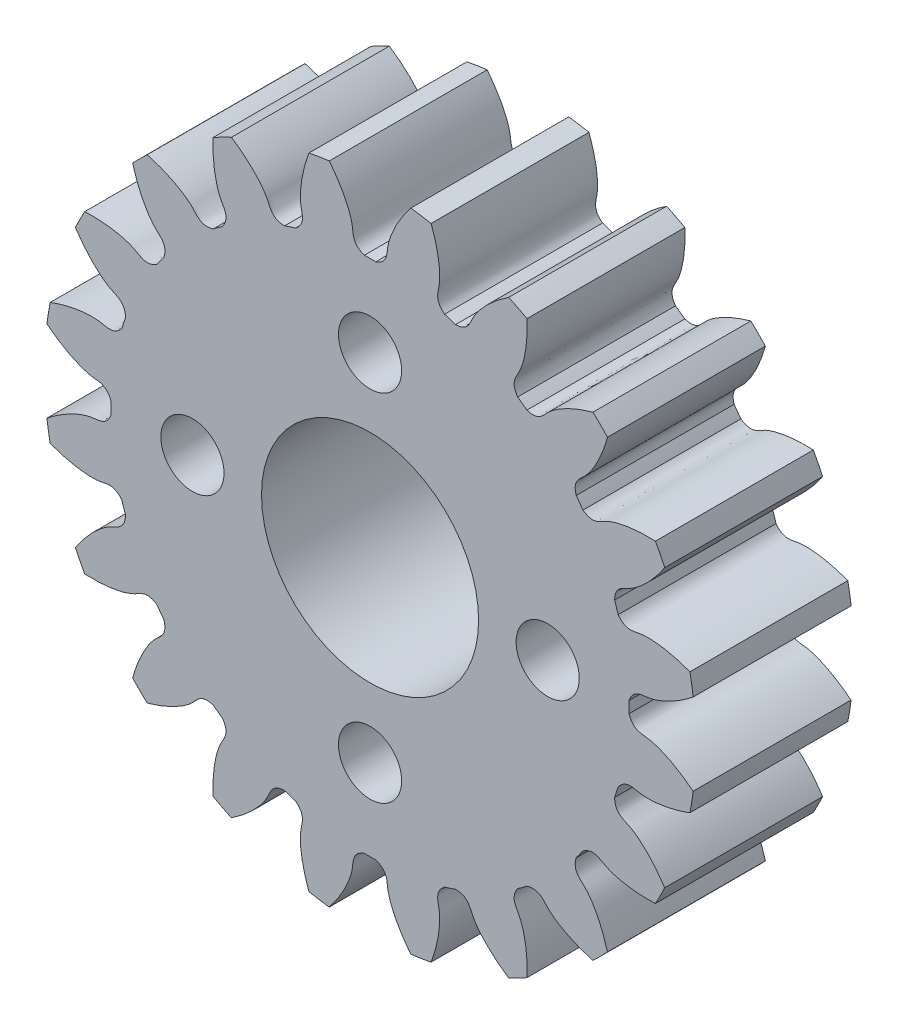
from build123d import *

# Parameters (mm, degrees)
SKETCH_1_R               = 16.5
EXTRUDE_1_DEPTH          = 10
CUT_EXTRUDE_1_DEPTH      = 11
PATTERN_CIRCULAR_1_COUNT = 20
SKETCH_4_R               = 1.6
SKETCH_4_R_2             = 5.5
CUT_EXTRUDE_2_DEPTH      = 11.0000001
CUT_EXTRUDE_3_DEPTH      = 2


with BuildPart() as part:
    # Sketch 1 → Extrude 1 (new body)
    with BuildSketch(Plane.XY):
        Circle(SKETCH_1_R)
    extrude(amount=EXTRUDE_1_DEPTH)

    # Sketch 2 → Cut-Extrude 1 (cut, through all)
    with BuildSketch(Plane.XY):
        with BuildLine():
            ThreePointArc((0.289974901, 13.121796354), (0, 13.125), (-0.289974901, 13.121796354))
            add(Edge.make_bspline(
                [(-0.289974901, 13.121796354), (-0.916784107, 13.340213268), (-0.835626149, 13.780670548), (-0.919345585, 14.205014104), (-0.928338279, 14.246334921), (-0.939466335, 14.292951923), (-0.952938145, 14.344795254), (-0.96896871, 14.401787245), (-0.987768083, 14.463844242), (-1.009544807, 14.5308761), (-1.034504625, 14.602786421), (-1.06285065, 14.679472568), (-1.094783098, 14.760825751), (-1.130499153, 14.846731096), (-1.170192797, 14.937067727), (-1.214054647, 15.031708847), (-1.2622718, 15.130521826), (-1.315027675, 15.233368292), (-1.372501858, 15.340104225), (-1.434869948, 15.450580056), (-1.502303414, 15.564640771), (-1.574969439, 15.682126017), (-1.653030782, 15.802870208), (-1.736645634, 15.926702646), (-1.825967477, 16.05344763), (-1.921144951, 16.182924586), (-2.022321721, 16.314948181), (-2.129636342, 16.449328459), (-2.24322214, 16.585870967), (-2.363207078, 16.724376892), (-2.489713645, 16.864643194), (-2.622858733, 17.006462752), (-2.762753527, 17.149624504), (-2.909503389, 17.29391359), (-3.06320776, 17.439111509), (-3.223960048, 17.584996263), (-3.391847534, 17.731342516), (-3.566951278, 17.877921749), (-3.749346018, 18.024502419), (-3.939100102, 18.170850122), (-4.136275349, 18.31672776), (-4.412210386, 18.512459802), (-4.625898619, 18.654498902), (-4.771736973, 18.747377789)],
                knots=[0, 0, 0, 0, 0.165916003, 0.170905922, 0.176663519, 0.183188797, 0.190481754, 0.198542391, 0.207370708, 0.216966704, 0.22733038, 0.238461736, 0.250360771, 0.263027487, 0.276461881, 0.290663956, 0.30563371, 0.321371144, 0.337876258, 0.355149051, 0.373189524, 0.391997677, 0.411573509, 0.431917021, 0.453028213, 0.474907084, 0.497553636, 0.520967867, 0.545149777, 0.570099367, 0.595816637, 0.622301587, 0.649554216, 0.677574526, 0.706362514, 0.735918183, 0.766241531, 0.797332559, 0.829191267, 0.861817654, 0.895211721, 0.929373468, 1, 1, 1, 1], degree=3))
            ThreePointArc((-4.771736973, 18.747377789), (0, 19.345119481), (4.771736973, 18.747377789))
            add(Edge.make_bspline(
                [(0.289974901, 13.121796354), (0.916784107, 13.340213268), (0.835626149, 13.780670548), (0.919345585, 14.205014104), (0.928338279, 14.246334921), (0.939466335, 14.292951923), (0.952938145, 14.344795254), (0.96896871, 14.401787245), (0.987768083, 14.463844242), (1.009544807, 14.5308761), (1.034504625, 14.602786421), (1.06285065, 14.679472568), (1.094783098, 14.760825751), (1.130499153, 14.846731096), (1.170192797, 14.937067727), (1.214054647, 15.031708847), (1.2622718, 15.130521826), (1.315027675, 15.233368292), (1.372501858, 15.340104225), (1.434869948, 15.450580056), (1.502303414, 15.564640771), (1.574969439, 15.682126017), (1.653030782, 15.802870208), (1.736645634, 15.926702646), (1.825967477, 16.05344763), (1.921144951, 16.182924586), (2.022321721, 16.314948181), (2.129636342, 16.449328459), (2.24322214, 16.585870967), (2.363207078, 16.724376892), (2.489713645, 16.864643194), (2.622858733, 17.006462752), (2.762753527, 17.149624504), (2.909503389, 17.29391359), (3.06320776, 17.439111509), (3.223960048, 17.584996263), (3.391847534, 17.731342516), (3.566951278, 17.877921749), (3.749346018, 18.024502419), (3.939100102, 18.170850122), (4.136275349, 18.31672776), (4.412210386, 18.512459802), (4.625898619, 18.654498902), (4.771736973, 18.747377789)],
                knots=[0, 0, 0, 0, 0.165916003, 0.170905922, 0.176663519, 0.183188797, 0.190481754, 0.198542391, 0.207370708, 0.216966704, 0.22733038, 0.238461736, 0.250360771, 0.263027487, 0.276461881, 0.290663956, 0.30563371, 0.321371144, 0.337876258, 0.355149051, 0.373189524, 0.391997677, 0.411573509, 0.431917021, 0.453028213, 0.474907084, 0.497553636, 0.520967867, 0.545149777, 0.570099367, 0.595816637, 0.622301587, 0.649554216, 0.677574526, 0.706362514, 0.735918183, 0.766241531, 0.797332559, 0.829191267, 0.861817654, 0.895211721, 0.929373468, 1, 1, 1, 1], degree=3))
        make_face()
    cut_extrude_1 = extrude(amount=CUT_EXTRUDE_1_DEPTH, mode=Mode.SUBTRACT)

    # Pattern Circular 1: Cut-Extrude 1 ×20 about axis
    pattern_circular_1_axis = Axis((0, 0, -0.6), (0, 0, 1))
    for i in range(1, PATTERN_CIRCULAR_1_COUNT):
        add(cut_extrude_1.rotate(pattern_circular_1_axis, i * 360 / PATTERN_CIRCULAR_1_COUNT), mode=Mode.SUBTRACT)

    # Sketch 4 → Cut-Extrude 2 (cut, through all)
    with BuildSketch(Plane.XY.offset(10)):
        with Locations((0, 9)):
            Circle(SKETCH_4_R)
        with Locations((9, 0)):
            Circle(SKETCH_4_R)
        with Locations((0, -9)):
            Circle(SKETCH_4_R)
        with Locations((-9, 0)):
            Circle(SKETCH_4_R)
        Circle(SKETCH_4_R_2)
    extrude(amount=-CUT_EXTRUDE_2_DEPTH, mode=Mode.SUBTRACT)

    # Sketch 5 → Cut-Extrude 3 (cut)
    with BuildSketch(Plane.XY.offset(10)):
        with BuildLine():
            ThreePointArc((-3.779075551, 12.5691771), (-4.055848051, 12.482616776), (-4.330640589, 12.389962756))
            add(Edge.make_bspline(
                [(-4.330640589, 12.389962756), (-4.994266108, 12.403994888), (-5.053189088, 12.847973843), (-5.271724722, 13.239628764), (-5.302663012, 13.291214284), (-5.339083547, 13.34823692), (-5.371941014, 13.397485807), (-5.423497094, 13.471517648), (-5.49921148, 13.573335394), (-5.605484405, 13.704968764), (-5.731774494, 13.849236955), (-5.879238162, 14.004722621), (-6.048949836, 14.16993691), (-6.241897634, 14.343324035), (-6.458979876, 14.523265777), (-6.701001692, 14.708086237), (-6.893090101, 14.842979081), (-7.003862907, 14.916928497), (-7.024032405, 14.930270218)],
                knots=[0.492568302, 0.492568302, 0.492568302, 0.492568302, 0.658484305, 0.663474224, 0.675757099, 0.683050056, 0.691110693, 0.69993901, 0.719898682, 0.742929074, 0.769030183, 0.798202012, 0.83044456, 0.865757826, 0.904141811, 0.945596515, 0.990121938, 1, 1, 1, 1], degree=3))
            ThreePointArc((-7.024032405, 14.930270218), (-7.490843246, 14.701607649), (-7.950219677, 14.458354231))
            add(Edge.make_bspline(
                [(-7.950219677, 14.458354231), (-7.956066747, 14.325295461), (-7.960919092, 14.090601088), (-7.95307581, 13.761985862), (-7.935097664, 13.480595511), (-7.908236426, 13.222583055), (-7.874329309, 12.988172883), (-7.835215787, 12.777480054), (-7.798771221, 12.617089507), (-7.762130708, 12.476113624), (-7.732718373, 12.375039504), (-7.702513172, 12.282091307), (-7.681245996, 12.220836149), (-7.660715943, 12.16530613), (-7.635991116, 12.102324233), (-7.612442624, 12.046973423), (-7.424039159, 11.639965394), (-7.099486698, 11.33133142), (-7.478203758, 10.786199217)],
                knots=[0, 0, 0, 0, 0.054403485, 0.095858189, 0.134242174, 0.16955544, 0.201797988, 0.230969817, 0.257070926, 0.268969962, 0.290464994, 0.30006099, 0.308889307, 0.316949944, 0.324242901, 0.336525776, 0.341515695, 0.507431698, 0.507431698, 0.507431698, 0.507431698], degree=3))
            ThreePointArc((-7.478203758, 10.786199217), (-7.714681436, 10.618348051), (-7.947393003, 10.445313277))
            add(Edge.make_bspline(
                [(-7.947393003, 10.445313277), (-8.582874544, 10.253587065), (-8.776110671, 10.657627941), (-9.104978437, 10.962582681), (-9.150343301, 11.002082969), (-9.202602252, 11.045060153), (-9.249070303, 11.081745113), (-9.320980145, 11.136221873), (-9.42445222, 11.209659272), (-9.566200726, 11.302009906), (-9.730891061, 11.400191325), (-9.919185056, 11.502498201), (-10.131644473, 11.607182537), (-10.368728301, 11.712459343), (-10.630790839, 11.816512007), (-10.918079927, 11.917497856), (-11.142451042, 11.986429991), (-11.270653866, 12.022529386), (-11.293959017, 12.028985398)],
                knots=[0.492568302, 0.492568302, 0.492568302, 0.492568302, 0.658484305, 0.663474224, 0.675757099, 0.683050056, 0.691110693, 0.69993901, 0.719898682, 0.742929074, 0.769030183, 0.798202012, 0.83044456, 0.865757826, 0.904141811, 0.945596515, 0.990121938, 1, 1, 1, 1], degree=3))
            ThreePointArc((-11.293959017, 12.028985398), (-11.66726189, 11.66726189), (-12.028985398, 11.293959017))
            add(Edge.make_bspline(
                [(-12.028985398, 11.293959017), (-11.993428871, 11.165605763), (-11.925519176, 10.940898693), (-11.816512081, 10.630790749), (-11.712459448, 10.368728174), (-11.607182659, 10.131644325), (-11.502498347, 9.91918488), (-11.400191512, 9.730890834), (-11.315967266, 9.589612349), (-11.237556123, 9.466858859), (-11.17834971, 9.37982057), (-11.120900284, 9.300755502), (-11.081745113, 9.249070303), (-11.045060153, 9.202602252), (-11.002082969, 9.150343301), (-10.962582681, 9.104978437), (-10.657627941, 8.776110671), (-10.253587065, 8.582874544), (-10.445313277, 7.947393003)],
                knots=[0, 0, 0, 0, 0.054403485, 0.095858189, 0.134242174, 0.16955544, 0.201797988, 0.230969817, 0.257070926, 0.268969962, 0.290464994, 0.30006099, 0.308889307, 0.316949944, 0.324242901, 0.336525776, 0.341515695, 0.507431698, 0.507431698, 0.507431698, 0.507431698], degree=3))
            ThreePointArc((-10.445313277, 7.947393003), (-10.618348051, 7.714681436), (-10.786199217, 7.478203758))
            add(Edge.make_bspline(
                [(-10.786199217, 7.478203758), (-11.33133142, 7.099486698), (-11.639965394, 7.424039159), (-12.046973423, 7.612442624), (-12.102324233, 7.635991116), (-12.16530613, 7.660715943), (-12.220836149, 7.681245996), (-12.306060717, 7.71083511), (-12.427161912, 7.748703597), (-12.590510669, 7.792731572), (-12.777480211, 7.835215538), (-12.988173006, 7.874329115), (-13.222583157, 7.908236264), (-13.480595599, 7.935097524), (-13.761985925, 7.953075711), (-14.066420428, 7.960341751), (-14.30111124, 7.956565619), (-14.434194698, 7.951281332), (-14.458354231, 7.950219677)],
                knots=[0.492568302, 0.492568302, 0.492568302, 0.492568302, 0.658484305, 0.663474224, 0.675757099, 0.683050056, 0.691110693, 0.69993901, 0.719898682, 0.742929074, 0.769030183, 0.798202012, 0.83044456, 0.865757826, 0.904141811, 0.945596515, 0.990121938, 1, 1, 1, 1], degree=3))
            ThreePointArc((-14.458354231, 7.950219677), (-14.701607649, 7.490843246), (-14.930270218, 7.024032405))
            add(Edge.make_bspline(
                [(-14.930270218, 7.024032405), (-14.856790614, 6.912948778), (-14.722766352, 6.720224904), (-14.52326582, 6.458979768), (-14.343324096, 6.24189748), (-14.169936981, 6.048949658), (-14.004722705, 5.879237949), (-13.849237063, 5.731774221), (-13.725477592, 5.623437121), (-13.612971249, 5.530921989), (-13.529766293, 5.466439445), (-13.450696193, 5.408996946), (-13.397485807, 5.371941014), (-13.34823692, 5.339083547), (-13.291214284, 5.302663012), (-13.239628764, 5.271724722), (-12.847973843, 5.053189088), (-12.403994888, 4.994266108), (-12.389962756, 4.330640589)],
                knots=[0, 0, 0, 0, 0.054403485, 0.095858189, 0.134242174, 0.16955544, 0.201797988, 0.230969817, 0.257070926, 0.268969962, 0.290464994, 0.30006099, 0.308889307, 0.316949944, 0.324242901, 0.336525776, 0.341515695, 0.507431698, 0.507431698, 0.507431698, 0.507431698], degree=3))
            ThreePointArc((-12.389962756, 4.330640589), (-12.482616776, 4.055848051), (-12.5691771, 3.779075551))
            add(Edge.make_bspline(
                [(-12.5691771, 3.779075551), (-12.970598627, 3.250439109), (-13.364419205, 3.463733699), (-13.809726715, 3.517143644), (-13.869645348, 3.522435249), (-13.937185083, 3.526487481), (-13.996341404, 3.528853002), (-14.086538325, 3.530658082), (-14.213414411, 3.529250826), (-14.382373703, 3.520646377), (-14.573320573, 3.503274264), (-14.785788088, 3.475365832), (-15.019203275, 3.435176726), (-15.272888275, 3.380993074), (-15.546061943, 3.311136952), (-15.837841691, 3.223971932), (-16.059879028, 3.147857168), (-16.184815984, 3.101706462), (-16.207464996, 3.093231062)],
                knots=[0.492568302, 0.492568302, 0.492568302, 0.492568302, 0.658484305, 0.663474224, 0.675757099, 0.683050056, 0.691110693, 0.69993901, 0.719898682, 0.742929074, 0.769030183, 0.798202012, 0.83044456, 0.865757826, 0.904141811, 0.945596515, 0.990121938, 1, 1, 1, 1], degree=3))
            ThreePointArc((-16.207464996, 3.093231062), (-16.29685762, 2.581168673), (-16.370076163, 2.066544562))
            add(Edge.make_bspline(
                [(-16.370076163, 2.066544562), (-16.265866178, 1.9836042), (-16.078846579, 1.841728679), (-15.80838111, 1.654918845), (-15.570164245, 1.504066371), (-15.345639144, 1.374141652), (-15.136067228, 1.263790245), (-14.942622797, 1.171591611), (-14.79144254, 1.106800686), (-14.655853902, 1.053579939), (-14.556795084, 1.017965141), (-14.463844242, 0.987768083), (-14.401787245, 0.96896871), (-14.344795254, 0.952938145), (-14.279308941, 0.935921121), (-14.220687739, 0.922437862), (-13.780670548, 0.835626149), (-13.340213268, 0.916784107), (-13.121796354, 0.289974901)],
                knots=[0, 0, 0, 0, 0.054403485, 0.095858189, 0.134242174, 0.16955544, 0.201797988, 0.230969817, 0.257070926, 0.268969962, 0.290464994, 0.30006099, 0.308889307, 0.316949944, 0.324242901, 0.336525776, 0.341515695, 0.507431698, 0.507431698, 0.507431698, 0.507431698], degree=3))
            ThreePointArc((-13.121796354, 0.289974901), (-13.125, 0), (-13.121796354, -0.289974901))
            add(Edge.make_bspline(
                [(-13.121796354, -0.289974901), (-13.340213268, -0.916784107), (-13.780670548, -0.835626149), (-14.220687739, -0.922437862), (-14.279308941, -0.935921121), (-14.344795254, -0.952938145), (-14.401787245, -0.96896871), (-14.488127415, -0.995124359), (-14.608358878, -1.035669605), (-14.766389792, -1.096064215), (-14.942622778, -1.171591904), (-15.136067213, -1.263790473), (-15.345639132, -1.374141844), (-15.570164235, -1.504066536), (-15.808381103, -1.654918961), (-16.05894466, -1.827982723), (-16.246593961, -1.968985475), (-16.351154715, -2.051485048), (-16.370076163, -2.066544562)],
                knots=[0.492568302, 0.492568302, 0.492568302, 0.492568302, 0.658484305, 0.663474224, 0.675757099, 0.683050056, 0.691110693, 0.69993901, 0.719898682, 0.742929074, 0.769030183, 0.798202012, 0.83044456, 0.865757826, 0.904141811, 0.945596515, 0.990121938, 1, 1, 1, 1], degree=3))
            ThreePointArc((-16.370076163, -2.066544562), (-16.29685762, -2.581168673), (-16.207464996, -3.093231062))
            add(Edge.make_bspline(
                [(-16.207464996, -3.093231062), (-16.08272543, -3.139909377), (-15.861017274, -3.217048781), (-15.546061914, -3.311137065), (-15.272888234, -3.380993234), (-15.019203228, -3.435176912), (-14.785788031, -3.475366054), (-14.5733205, -3.503274549), (-14.409518034, -3.518177112), (-14.264119461, -3.526893856), (-14.15890335, -3.530154684), (-14.061170441, -3.530150403), (-13.996341404, -3.528853002), (-13.937185083, -3.526487481), (-13.869645348, -3.522435249), (-13.809726715, -3.517143644), (-13.364419205, -3.463733699), (-12.970598627, -3.250439109), (-12.5691771, -3.779075551)],
                knots=[0, 0, 0, 0, 0.054403485, 0.095858189, 0.134242174, 0.16955544, 0.201797988, 0.230969817, 0.257070926, 0.268969962, 0.290464994, 0.30006099, 0.308889307, 0.316949944, 0.324242901, 0.336525776, 0.341515695, 0.507431698, 0.507431698, 0.507431698, 0.507431698], degree=3))
            ThreePointArc((-12.5691771, -3.779075551), (-12.482616776, -4.055848051), (-12.389962756, -4.330640589))
            add(Edge.make_bspline(
                [(-12.389962756, -4.330640589), (-12.403994888, -4.994266108), (-12.847973843, -5.053189088), (-13.239628764, -5.271724722), (-13.291214284, -5.302663012), (-13.34823692, -5.339083547), (-13.397485807, -5.371941014), (-13.471517648, -5.423497094), (-13.573335394, -5.49921148), (-13.704968764, -5.605484405), (-13.849236955, -5.731774494), (-14.004722621, -5.879238162), (-14.16993691, -6.048949836), (-14.343324035, -6.241897634), (-14.523265777, -6.458979876), (-14.708086237, -6.701001692), (-14.842979081, -6.893090101), (-14.916928497, -7.003862907), (-14.930270218, -7.024032405)],
                knots=[0.492568302, 0.492568302, 0.492568302, 0.492568302, 0.658484305, 0.663474224, 0.675757099, 0.683050056, 0.691110693, 0.69993901, 0.719898682, 0.742929074, 0.769030183, 0.798202012, 0.83044456, 0.865757826, 0.904141811, 0.945596515, 0.990121938, 1, 1, 1, 1], degree=3))
            ThreePointArc((-14.930270218, -7.024032405), (-14.701607649, -7.490843246), (-14.458354231, -7.950219677))
            add(Edge.make_bspline(
                [(-14.458354231, -7.950219677), (-14.325295461, -7.956066747), (-14.090601088, -7.960919092), (-13.761985862, -7.95307581), (-13.480595511, -7.935097664), (-13.222583055, -7.908236426), (-12.988172883, -7.874329309), (-12.777480054, -7.835215787), (-12.617089507, -7.798771221), (-12.476113624, -7.762130708), (-12.375039504, -7.732718373), (-12.282091307, -7.702513172), (-12.220836149, -7.681245996), (-12.16530613, -7.660715943), (-12.102324233, -7.635991116), (-12.046973423, -7.612442624), (-11.639965394, -7.424039159), (-11.33133142, -7.099486698), (-10.786199217, -7.478203758)],
                knots=[0, 0, 0, 0, 0.054403485, 0.095858189, 0.134242174, 0.16955544, 0.201797988, 0.230969817, 0.257070926, 0.268969962, 0.290464994, 0.30006099, 0.308889307, 0.316949944, 0.324242901, 0.336525776, 0.341515695, 0.507431698, 0.507431698, 0.507431698, 0.507431698], degree=3))
            ThreePointArc((-10.786199217, -7.478203758), (-10.618348051, -7.714681436), (-10.445313277, -7.947393003))
            add(Edge.make_bspline(
                [(-10.445313277, -7.947393003), (-10.253587065, -8.582874544), (-10.657627941, -8.776110671), (-10.962582681, -9.104978437), (-11.002082969, -9.150343301), (-11.045060153, -9.202602252), (-11.081745113, -9.249070303), (-11.136221873, -9.320980145), (-11.209659272, -9.42445222), (-11.302009906, -9.566200726), (-11.400191325, -9.730891061), (-11.502498201, -9.919185056), (-11.607182537, -10.131644473), (-11.712459343, -10.368728301), (-11.816512007, -10.630790839), (-11.917497856, -10.918079927), (-11.986429991, -11.142451042), (-12.022529386, -11.270653866), (-12.028985398, -11.293959017)],
                knots=[0.492568302, 0.492568302, 0.492568302, 0.492568302, 0.658484305, 0.663474224, 0.675757099, 0.683050056, 0.691110693, 0.69993901, 0.719898682, 0.742929074, 0.769030183, 0.798202012, 0.83044456, 0.865757826, 0.904141811, 0.945596515, 0.990121938, 1, 1, 1, 1], degree=3))
            ThreePointArc((-12.028985398, -11.293959017), (-11.66726189, -11.66726189), (-11.293959017, -12.028985398))
            add(Edge.make_bspline(
                [(-11.293959017, -12.028985398), (-11.165605763, -11.993428871), (-10.940898693, -11.925519176), (-10.630790749, -11.816512081), (-10.368728174, -11.712459448), (-10.131644325, -11.607182659), (-9.91918488, -11.502498347), (-9.730890834, -11.400191512), (-9.589612349, -11.315967266), (-9.466858859, -11.237556123), (-9.37982057, -11.17834971), (-9.300755502, -11.120900284), (-9.249070303, -11.081745113), (-9.202602252, -11.045060153), (-9.150343301, -11.002082969), (-9.104978437, -10.962582681), (-8.776110671, -10.657627941), (-8.582874544, -10.253587065), (-7.947393003, -10.445313277)],
                knots=[0, 0, 0, 0, 0.054403485, 0.095858189, 0.134242174, 0.16955544, 0.201797988, 0.230969817, 0.257070926, 0.268969962, 0.290464994, 0.30006099, 0.308889307, 0.316949944, 0.324242901, 0.336525776, 0.341515695, 0.507431698, 0.507431698, 0.507431698, 0.507431698], degree=3))
            ThreePointArc((-7.947393003, -10.445313277), (-7.714681436, -10.618348051), (-7.478203758, -10.786199217))
            add(Edge.make_bspline(
                [(-7.478203758, -10.786199217), (-7.099486698, -11.33133142), (-7.424039159, -11.639965394), (-7.612442624, -12.046973423), (-7.635991116, -12.102324233), (-7.660715943, -12.16530613), (-7.681245996, -12.220836149), (-7.71083511, -12.306060717), (-7.748703597, -12.427161912), (-7.792731572, -12.590510669), (-7.835215538, -12.777480211), (-7.874329115, -12.988173006), (-7.908236264, -13.222583157), (-7.935097524, -13.480595599), (-7.953075711, -13.761985925), (-7.960341751, -14.066420428), (-7.956565619, -14.30111124), (-7.951281332, -14.434194698), (-7.950219677, -14.458354231)],
                knots=[0.492568302, 0.492568302, 0.492568302, 0.492568302, 0.658484305, 0.663474224, 0.675757099, 0.683050056, 0.691110693, 0.69993901, 0.719898682, 0.742929074, 0.769030183, 0.798202012, 0.83044456, 0.865757826, 0.904141811, 0.945596515, 0.990121938, 1, 1, 1, 1], degree=3))
            ThreePointArc((-7.950219677, -14.458354231), (-7.490843246, -14.701607649), (-7.024032405, -14.930270218))
            add(Edge.make_bspline(
                [(-7.024032405, -14.930270218), (-6.912948778, -14.856790614), (-6.720224904, -14.722766352), (-6.458979768, -14.52326582), (-6.24189748, -14.343324096), (-6.048949658, -14.169936981), (-5.879237949, -14.004722705), (-5.731774221, -13.849237063), (-5.623437121, -13.725477592), (-5.530921989, -13.612971249), (-5.466439445, -13.529766293), (-5.408996946, -13.450696193), (-5.371941014, -13.397485807), (-5.339083547, -13.34823692), (-5.302663012, -13.291214284), (-5.271724722, -13.239628764), (-5.053189088, -12.847973843), (-4.994266108, -12.403994888), (-4.330640589, -12.389962756)],
                knots=[0, 0, 0, 0, 0.054403485, 0.095858189, 0.134242174, 0.16955544, 0.201797988, 0.230969817, 0.257070926, 0.268969962, 0.290464994, 0.30006099, 0.308889307, 0.316949944, 0.324242901, 0.336525776, 0.341515695, 0.507431698, 0.507431698, 0.507431698, 0.507431698], degree=3))
            ThreePointArc((-4.330640589, -12.389962756), (-4.055848051, -12.482616776), (-3.779075551, -12.5691771))
            add(Edge.make_bspline(
                [(-3.779075551, -12.5691771), (-3.250439109, -12.970598627), (-3.463733699, -13.364419205), (-3.517143644, -13.809726715), (-3.522435249, -13.869645348), (-3.526487481, -13.937185083), (-3.528853002, -13.996341404), (-3.530658082, -14.086538325), (-3.529250826, -14.213414411), (-3.520646377, -14.382373703), (-3.503274264, -14.573320573), (-3.475365832, -14.785788088), (-3.435176726, -15.019203275), (-3.380993074, -15.272888275), (-3.311136952, -15.546061943), (-3.223971932, -15.837841691), (-3.147857168, -16.059879028), (-3.101706462, -16.184815984), (-3.093231062, -16.207464996)],
                knots=[0.492568302, 0.492568302, 0.492568302, 0.492568302, 0.658484305, 0.663474224, 0.675757099, 0.683050056, 0.691110693, 0.69993901, 0.719898682, 0.742929074, 0.769030183, 0.798202012, 0.83044456, 0.865757826, 0.904141811, 0.945596515, 0.990121938, 1, 1, 1, 1], degree=3))
            ThreePointArc((-3.093231062, -16.207464996), (-2.581168673, -16.29685762), (-2.066544562, -16.370076163))
            add(Edge.make_bspline(
                [(-2.066544562, -16.370076163), (-1.9836042, -16.265866178), (-1.841728679, -16.078846579), (-1.654918845, -15.80838111), (-1.504066371, -15.570164245), (-1.374141652, -15.345639144), (-1.263790245, -15.136067228), (-1.171591611, -14.942622797), (-1.106800686, -14.79144254), (-1.053579939, -14.655853902), (-1.017965141, -14.556795084), (-0.987768083, -14.463844242), (-0.96896871, -14.401787245), (-0.952938145, -14.344795254), (-0.935921121, -14.279308941), (-0.922437862, -14.220687739), (-0.835626149, -13.780670548), (-0.916784107, -13.340213268), (-0.289974901, -13.121796354)],
                knots=[0, 0, 0, 0, 0.054403485, 0.095858189, 0.134242174, 0.16955544, 0.201797988, 0.230969817, 0.257070926, 0.268969962, 0.290464994, 0.30006099, 0.308889307, 0.316949944, 0.324242901, 0.336525776, 0.341515695, 0.507431698, 0.507431698, 0.507431698, 0.507431698], degree=3))
            ThreePointArc((-0.289974901, -13.121796354), (0, -13.125), (0.289974901, -13.121796354))
            add(Edge.make_bspline(
                [(0.289974901, -13.121796354), (0.916784107, -13.340213268), (0.835626149, -13.780670548), (0.922437862, -14.220687739), (0.935921121, -14.279308941), (0.952938145, -14.344795254), (0.96896871, -14.401787245), (0.995124359, -14.488127415), (1.035669605, -14.608358878), (1.096064215, -14.766389792), (1.171591904, -14.942622778), (1.263790473, -15.136067213), (1.374141844, -15.345639132), (1.504066536, -15.570164235), (1.654918961, -15.808381103), (1.827982723, -16.05894466), (1.968985475, -16.246593961), (2.051485048, -16.351154715), (2.066544562, -16.370076163)],
                knots=[0.492568302, 0.492568302, 0.492568302, 0.492568302, 0.658484305, 0.663474224, 0.675757099, 0.683050056, 0.691110693, 0.69993901, 0.719898682, 0.742929074, 0.769030183, 0.798202012, 0.83044456, 0.865757826, 0.904141811, 0.945596515, 0.990121938, 1, 1, 1, 1], degree=3))
            ThreePointArc((2.066544562, -16.370076163), (2.581168673, -16.29685762), (3.093231062, -16.207464996))
            add(Edge.make_bspline(
                [(3.093231062, -16.207464996), (3.139909377, -16.08272543), (3.217048781, -15.861017274), (3.311137065, -15.546061914), (3.380993234, -15.272888234), (3.435176912, -15.019203228), (3.475366054, -14.785788031), (3.503274549, -14.5733205), (3.518177112, -14.409518034), (3.526893856, -14.264119461), (3.530154684, -14.15890335), (3.530150403, -14.061170441), (3.528853002, -13.996341404), (3.526487481, -13.937185083), (3.522435249, -13.869645348), (3.517143644, -13.809726715), (3.463733699, -13.364419205), (3.250439109, -12.970598627), (3.779075551, -12.5691771)],
                knots=[0, 0, 0, 0, 0.054403485, 0.095858189, 0.134242174, 0.16955544, 0.201797988, 0.230969817, 0.257070926, 0.268969962, 0.290464994, 0.30006099, 0.308889307, 0.316949944, 0.324242901, 0.336525776, 0.341515695, 0.507431698, 0.507431698, 0.507431698, 0.507431698], degree=3))
            ThreePointArc((3.779075551, -12.5691771), (4.055848051, -12.482616776), (4.330640589, -12.389962756))
            add(Edge.make_bspline(
                [(4.330640589, -12.389962756), (4.994266108, -12.403994888), (5.053189088, -12.847973843), (5.271724722, -13.239628764), (5.302663012, -13.291214284), (5.339083547, -13.34823692), (5.371941014, -13.397485807), (5.423497094, -13.471517648), (5.49921148, -13.573335394), (5.605484405, -13.704968764), (5.731774494, -13.849236955), (5.879238162, -14.004722621), (6.048949836, -14.16993691), (6.241897634, -14.343324035), (6.458979876, -14.523265777), (6.701001692, -14.708086237), (6.893090101, -14.842979081), (7.003862907, -14.916928497), (7.024032405, -14.930270218)],
                knots=[0.492568302, 0.492568302, 0.492568302, 0.492568302, 0.658484305, 0.663474224, 0.675757099, 0.683050056, 0.691110693, 0.69993901, 0.719898682, 0.742929074, 0.769030183, 0.798202012, 0.83044456, 0.865757826, 0.904141811, 0.945596515, 0.990121938, 1, 1, 1, 1], degree=3))
            ThreePointArc((7.024032405, -14.930270218), (7.490843246, -14.701607649), (7.950219677, -14.458354231))
            add(Edge.make_bspline(
                [(7.950219677, -14.458354231), (7.956066747, -14.325295461), (7.960919092, -14.090601088), (7.95307581, -13.761985862), (7.935097664, -13.480595511), (7.908236426, -13.222583055), (7.874329309, -12.988172883), (7.835215787, -12.777480054), (7.798771221, -12.617089507), (7.762130708, -12.476113624), (7.732718373, -12.375039504), (7.702513172, -12.282091307), (7.681245996, -12.220836149), (7.660715943, -12.16530613), (7.635991116, -12.102324233), (7.612442624, -12.046973423), (7.424039159, -11.639965394), (7.099486698, -11.33133142), (7.478203758, -10.786199217)],
                knots=[0, 0, 0, 0, 0.054403485, 0.095858189, 0.134242174, 0.16955544, 0.201797988, 0.230969817, 0.257070926, 0.268969962, 0.290464994, 0.30006099, 0.308889307, 0.316949944, 0.324242901, 0.336525776, 0.341515695, 0.507431698, 0.507431698, 0.507431698, 0.507431698], degree=3))
            ThreePointArc((7.478203758, -10.786199217), (7.714681436, -10.618348051), (7.947393003, -10.445313277))
            add(Edge.make_bspline(
                [(7.947393003, -10.445313277), (8.582874544, -10.253587065), (8.776110671, -10.657627941), (9.104978437, -10.962582681), (9.150343301, -11.002082969), (9.202602252, -11.045060153), (9.249070303, -11.081745113), (9.320980145, -11.136221873), (9.42445222, -11.209659272), (9.566200726, -11.302009906), (9.730891061, -11.400191325), (9.919185056, -11.502498201), (10.131644473, -11.607182537), (10.368728301, -11.712459343), (10.630790839, -11.816512007), (10.918079927, -11.917497856), (11.142451042, -11.986429991), (11.270653866, -12.022529386), (11.293959017, -12.028985398)],
                knots=[0.492568302, 0.492568302, 0.492568302, 0.492568302, 0.658484305, 0.663474224, 0.675757099, 0.683050056, 0.691110693, 0.69993901, 0.719898682, 0.742929074, 0.769030183, 0.798202012, 0.83044456, 0.865757826, 0.904141811, 0.945596515, 0.990121938, 1, 1, 1, 1], degree=3))
            ThreePointArc((11.293959017, -12.028985398), (11.66726189, -11.66726189), (12.028985398, -11.293959017))
            add(Edge.make_bspline(
                [(12.028985398, -11.293959017), (11.993428871, -11.165605763), (11.925519176, -10.940898693), (11.816512081, -10.630790749), (11.712459448, -10.368728174), (11.607182659, -10.131644325), (11.502498347, -9.91918488), (11.400191512, -9.730890834), (11.315967266, -9.589612349), (11.237556123, -9.466858859), (11.17834971, -9.37982057), (11.120900284, -9.300755502), (11.081745113, -9.249070303), (11.045060153, -9.202602252), (11.002082969, -9.150343301), (10.962582681, -9.104978437), (10.657627941, -8.776110671), (10.253587065, -8.582874544), (10.445313277, -7.947393003)],
                knots=[0, 0, 0, 0, 0.054403485, 0.095858189, 0.134242174, 0.16955544, 0.201797988, 0.230969817, 0.257070926, 0.268969962, 0.290464994, 0.30006099, 0.308889307, 0.316949944, 0.324242901, 0.336525776, 0.341515695, 0.507431698, 0.507431698, 0.507431698, 0.507431698], degree=3))
            ThreePointArc((10.445313277, -7.947393003), (10.618348051, -7.714681436), (10.786199217, -7.478203758))
            add(Edge.make_bspline(
                [(10.786199217, -7.478203758), (11.33133142, -7.099486698), (11.639965394, -7.424039159), (12.046973423, -7.612442624), (12.102324233, -7.635991116), (12.16530613, -7.660715943), (12.220836149, -7.681245996), (12.306060717, -7.71083511), (12.427161912, -7.748703597), (12.590510669, -7.792731572), (12.777480211, -7.835215538), (12.988173006, -7.874329115), (13.222583157, -7.908236264), (13.480595599, -7.935097524), (13.761985925, -7.953075711), (14.066420428, -7.960341751), (14.30111124, -7.956565619), (14.434194698, -7.951281332), (14.458354231, -7.950219677)],
                knots=[0.492568302, 0.492568302, 0.492568302, 0.492568302, 0.658484305, 0.663474224, 0.675757099, 0.683050056, 0.691110693, 0.69993901, 0.719898682, 0.742929074, 0.769030183, 0.798202012, 0.83044456, 0.865757826, 0.904141811, 0.945596515, 0.990121938, 1, 1, 1, 1], degree=3))
            ThreePointArc((14.458354231, -7.950219677), (14.701607649, -7.490843246), (14.930270218, -7.024032405))
            add(Edge.make_bspline(
                [(14.930270218, -7.024032405), (14.856790614, -6.912948778), (14.722766352, -6.720224904), (14.52326582, -6.458979768), (14.343324096, -6.24189748), (14.169936981, -6.048949658), (14.004722705, -5.879237949), (13.849237063, -5.731774221), (13.725477592, -5.623437121), (13.612971249, -5.530921989), (13.529766293, -5.466439445), (13.450696193, -5.408996946), (13.397485807, -5.371941014), (13.34823692, -5.339083547), (13.291214284, -5.302663012), (13.239628764, -5.271724722), (12.847973843, -5.053189088), (12.403994888, -4.994266108), (12.389962756, -4.330640589)],
                knots=[0, 0, 0, 0, 0.054403485, 0.095858189, 0.134242174, 0.16955544, 0.201797988, 0.230969817, 0.257070926, 0.268969962, 0.290464994, 0.30006099, 0.308889307, 0.316949944, 0.324242901, 0.336525776, 0.341515695, 0.507431698, 0.507431698, 0.507431698, 0.507431698], degree=3))
            ThreePointArc((12.389962756, -4.330640589), (12.482616776, -4.055848051), (12.5691771, -3.779075551))
            add(Edge.make_bspline(
                [(12.5691771, -3.779075551), (12.970598627, -3.250439109), (13.364419205, -3.463733699), (13.809726715, -3.517143644), (13.869645348, -3.522435249), (13.937185083, -3.526487481), (13.996341404, -3.528853002), (14.086538325, -3.530658082), (14.213414411, -3.529250826), (14.382373703, -3.520646377), (14.573320573, -3.503274264), (14.785788088, -3.475365832), (15.019203275, -3.435176726), (15.272888275, -3.380993074), (15.546061943, -3.311136952), (15.837841691, -3.223971932), (16.059879028, -3.147857168), (16.184815984, -3.101706462), (16.207464996, -3.093231062)],
                knots=[0.492568302, 0.492568302, 0.492568302, 0.492568302, 0.658484305, 0.663474224, 0.675757099, 0.683050056, 0.691110693, 0.69993901, 0.719898682, 0.742929074, 0.769030183, 0.798202012, 0.83044456, 0.865757826, 0.904141811, 0.945596515, 0.990121938, 1, 1, 1, 1], degree=3))
            ThreePointArc((16.207464996, -3.093231062), (16.29685762, -2.581168673), (16.370076163, -2.066544562))
            add(Edge.make_bspline(
                [(16.370076163, -2.066544562), (16.265866178, -1.9836042), (16.078846579, -1.841728679), (15.80838111, -1.654918845), (15.570164245, -1.504066371), (15.345639144, -1.374141652), (15.136067228, -1.263790245), (14.942622797, -1.171591611), (14.79144254, -1.106800686), (14.655853902, -1.053579939), (14.556795084, -1.017965141), (14.463844242, -0.987768083), (14.401787245, -0.96896871), (14.344795254, -0.952938145), (14.279308941, -0.935921121), (14.220687739, -0.922437862), (13.780670548, -0.835626149), (13.340213268, -0.916784107), (13.121796354, -0.289974901)],
                knots=[0, 0, 0, 0, 0.054403485, 0.095858189, 0.134242174, 0.16955544, 0.201797988, 0.230969817, 0.257070926, 0.268969962, 0.290464994, 0.30006099, 0.308889307, 0.316949944, 0.324242901, 0.336525776, 0.341515695, 0.507431698, 0.507431698, 0.507431698, 0.507431698], degree=3))
            ThreePointArc((13.121796354, -0.289974901), (13.125, 0), (13.121796354, 0.289974901))
            add(Edge.make_bspline(
                [(13.121796354, 0.289974901), (13.340213268, 0.916784107), (13.780670548, 0.835626149), (14.220687739, 0.922437862), (14.279308941, 0.935921121), (14.344795254, 0.952938145), (14.401787245, 0.96896871), (14.488127415, 0.995124359), (14.608358878, 1.035669605), (14.766389792, 1.096064215), (14.942622778, 1.171591904), (15.136067213, 1.263790473), (15.345639132, 1.374141844), (15.570164235, 1.504066536), (15.808381103, 1.654918961), (16.05894466, 1.827982723), (16.246593961, 1.968985475), (16.351154715, 2.051485048), (16.370076163, 2.066544562)],
                knots=[0.492568302, 0.492568302, 0.492568302, 0.492568302, 0.658484305, 0.663474224, 0.675757099, 0.683050056, 0.691110693, 0.69993901, 0.719898682, 0.742929074, 0.769030183, 0.798202012, 0.83044456, 0.865757826, 0.904141811, 0.945596515, 0.990121938, 1, 1, 1, 1], degree=3))
            ThreePointArc((16.370076163, 2.066544562), (16.29685762, 2.581168673), (16.207464996, 3.093231062))
            add(Edge.make_bspline(
                [(16.207464996, 3.093231062), (16.08272543, 3.139909377), (15.861017274, 3.217048781), (15.546061914, 3.311137065), (15.272888234, 3.380993234), (15.019203228, 3.435176912), (14.785788031, 3.475366054), (14.5733205, 3.503274549), (14.409518034, 3.518177112), (14.264119461, 3.526893856), (14.15890335, 3.530154684), (14.061170441, 3.530150403), (13.996341404, 3.528853002), (13.937185083, 3.526487481), (13.869645348, 3.522435249), (13.809726715, 3.517143644), (13.364419205, 3.463733699), (12.970598627, 3.250439109), (12.5691771, 3.779075551)],
                knots=[0, 0, 0, 0, 0.054403485, 0.095858189, 0.134242174, 0.16955544, 0.201797988, 0.230969817, 0.257070926, 0.268969962, 0.290464994, 0.30006099, 0.308889307, 0.316949944, 0.324242901, 0.336525776, 0.341515695, 0.507431698, 0.507431698, 0.507431698, 0.507431698], degree=3))
            ThreePointArc((12.5691771, 3.779075551), (12.482616776, 4.055848051), (12.389962756, 4.330640589))
            add(Edge.make_bspline(
                [(12.389962756, 4.330640589), (12.403994888, 4.994266108), (12.847973843, 5.053189088), (13.239628764, 5.271724722), (13.291214284, 5.302663012), (13.34823692, 5.339083547), (13.397485807, 5.371941014), (13.471517648, 5.423497094), (13.573335394, 5.49921148), (13.704968764, 5.605484405), (13.849236955, 5.731774494), (14.004722621, 5.879238162), (14.16993691, 6.048949836), (14.343324035, 6.241897634), (14.523265777, 6.458979876), (14.708086237, 6.701001692), (14.842979081, 6.893090101), (14.916928497, 7.003862907), (14.930270218, 7.024032405)],
                knots=[0.492568302, 0.492568302, 0.492568302, 0.492568302, 0.658484305, 0.663474224, 0.675757099, 0.683050056, 0.691110693, 0.69993901, 0.719898682, 0.742929074, 0.769030183, 0.798202012, 0.83044456, 0.865757826, 0.904141811, 0.945596515, 0.990121938, 1, 1, 1, 1], degree=3))
            ThreePointArc((14.930270218, 7.024032405), (14.701607649, 7.490843246), (14.458354231, 7.950219677))
            add(Edge.make_bspline(
                [(14.458354231, 7.950219677), (14.325295461, 7.956066747), (14.090601088, 7.960919092), (13.761985862, 7.95307581), (13.480595511, 7.935097664), (13.222583055, 7.908236426), (12.988172883, 7.874329309), (12.777480054, 7.835215787), (12.617089507, 7.798771221), (12.476113624, 7.762130708), (12.375039504, 7.732718373), (12.282091307, 7.702513172), (12.220836149, 7.681245996), (12.16530613, 7.660715943), (12.102324233, 7.635991116), (12.046973423, 7.612442624), (11.639965394, 7.424039159), (11.33133142, 7.099486698), (10.786199217, 7.478203758)],
                knots=[0, 0, 0, 0, 0.054403485, 0.095858189, 0.134242174, 0.16955544, 0.201797988, 0.230969817, 0.257070926, 0.268969962, 0.290464994, 0.30006099, 0.308889307, 0.316949944, 0.324242901, 0.336525776, 0.341515695, 0.507431698, 0.507431698, 0.507431698, 0.507431698], degree=3))
            ThreePointArc((10.786199217, 7.478203758), (10.618348051, 7.714681436), (10.445313277, 7.947393003))
            add(Edge.make_bspline(
                [(10.445313277, 7.947393003), (10.253587065, 8.582874544), (10.657627941, 8.776110671), (10.962582681, 9.104978437), (11.002082969, 9.150343301), (11.045060153, 9.202602252), (11.081745113, 9.249070303), (11.136221873, 9.320980145), (11.209659272, 9.42445222), (11.302009906, 9.566200726), (11.400191325, 9.730891061), (11.502498201, 9.919185056), (11.607182537, 10.131644473), (11.712459343, 10.368728301), (11.816512007, 10.630790839), (11.917497856, 10.918079927), (11.986429991, 11.142451042), (12.022529386, 11.270653866), (12.028985398, 11.293959017)],
                knots=[0.492568302, 0.492568302, 0.492568302, 0.492568302, 0.658484305, 0.663474224, 0.675757099, 0.683050056, 0.691110693, 0.69993901, 0.719898682, 0.742929074, 0.769030183, 0.798202012, 0.83044456, 0.865757826, 0.904141811, 0.945596515, 0.990121938, 1, 1, 1, 1], degree=3))
            ThreePointArc((12.028985398, 11.293959017), (11.66726189, 11.66726189), (11.293959017, 12.028985398))
            add(Edge.make_bspline(
                [(11.293959017, 12.028985398), (11.165605763, 11.993428871), (10.940898693, 11.925519176), (10.630790749, 11.816512081), (10.368728174, 11.712459448), (10.131644325, 11.607182659), (9.91918488, 11.502498347), (9.730890834, 11.400191512), (9.589612349, 11.315967266), (9.466858859, 11.237556123), (9.37982057, 11.17834971), (9.300755502, 11.120900284), (9.249070303, 11.081745113), (9.202602252, 11.045060153), (9.150343301, 11.002082969), (9.104978437, 10.962582681), (8.776110671, 10.657627941), (8.582874544, 10.253587065), (7.947393003, 10.445313277)],
                knots=[0, 0, 0, 0, 0.054403485, 0.095858189, 0.134242174, 0.16955544, 0.201797988, 0.230969817, 0.257070926, 0.268969962, 0.290464994, 0.30006099, 0.308889307, 0.316949944, 0.324242901, 0.336525776, 0.341515695, 0.507431698, 0.507431698, 0.507431698, 0.507431698], degree=3))
            ThreePointArc((7.947393003, 10.445313277), (7.714681436, 10.618348051), (7.478203758, 10.786199217))
            add(Edge.make_bspline(
                [(7.478203758, 10.786199217), (7.099486698, 11.33133142), (7.424039159, 11.639965394), (7.612442624, 12.046973423), (7.635991116, 12.102324233), (7.660715943, 12.16530613), (7.681245996, 12.220836149), (7.71083511, 12.306060717), (7.748703597, 12.427161912), (7.792731572, 12.590510669), (7.835215538, 12.777480211), (7.874329115, 12.988173006), (7.908236264, 13.222583157), (7.935097524, 13.480595599), (7.953075711, 13.761985925), (7.960341751, 14.066420428), (7.956565619, 14.30111124), (7.951281332, 14.434194698), (7.950219677, 14.458354231)],
                knots=[0.492568302, 0.492568302, 0.492568302, 0.492568302, 0.658484305, 0.663474224, 0.675757099, 0.683050056, 0.691110693, 0.69993901, 0.719898682, 0.742929074, 0.769030183, 0.798202012, 0.83044456, 0.865757826, 0.904141811, 0.945596515, 0.990121938, 1, 1, 1, 1], degree=3))
            ThreePointArc((7.950219677, 14.458354231), (7.490843246, 14.701607649), (7.024032405, 14.930270218))
            add(Edge.make_bspline(
                [(7.024032405, 14.930270218), (6.912948778, 14.856790614), (6.720224904, 14.722766352), (6.458979768, 14.52326582), (6.24189748, 14.343324096), (6.048949658, 14.169936981), (5.879237949, 14.004722705), (5.731774221, 13.849237063), (5.623437121, 13.725477592), (5.530921989, 13.612971249), (5.466439445, 13.529766293), (5.408996946, 13.450696193), (5.371941014, 13.397485807), (5.339083547, 13.34823692), (5.302663012, 13.291214284), (5.271724722, 13.239628764), (5.053189088, 12.847973843), (4.994266108, 12.403994888), (4.330640589, 12.389962756)],
                knots=[0, 0, 0, 0, 0.054403485, 0.095858189, 0.134242174, 0.16955544, 0.201797988, 0.230969817, 0.257070926, 0.268969962, 0.290464994, 0.30006099, 0.308889307, 0.316949944, 0.324242901, 0.336525776, 0.341515695, 0.507431698, 0.507431698, 0.507431698, 0.507431698], degree=3))
            ThreePointArc((4.330640589, 12.389962756), (4.055848051, 12.482616776), (3.779075551, 12.5691771))
            add(Edge.make_bspline(
                [(3.779075551, 12.5691771), (3.250439109, 12.970598627), (3.463733699, 13.364419205), (3.517143644, 13.809726715), (3.522435249, 13.869645348), (3.526487481, 13.937185083), (3.528853002, 13.996341404), (3.530658082, 14.086538325), (3.529250826, 14.213414411), (3.520646377, 14.382373703), (3.503274264, 14.573320573), (3.475365832, 14.785788088), (3.435176726, 15.019203275), (3.380993074, 15.272888275), (3.311136952, 15.546061943), (3.223971932, 15.837841691), (3.147857168, 16.059879028), (3.101706462, 16.184815984), (3.093231062, 16.207464996)],
                knots=[0.492568302, 0.492568302, 0.492568302, 0.492568302, 0.658484305, 0.663474224, 0.675757099, 0.683050056, 0.691110693, 0.69993901, 0.719898682, 0.742929074, 0.769030183, 0.798202012, 0.83044456, 0.865757826, 0.904141811, 0.945596515, 0.990121938, 1, 1, 1, 1], degree=3))
            ThreePointArc((3.093231062, 16.207464996), (2.581168673, 16.29685762), (2.066544562, 16.370076163))
            add(Edge.make_bspline(
                [(2.066544562, 16.370076163), (1.9836042, 16.265866178), (1.841728679, 16.078846579), (1.654918845, 15.80838111), (1.504066371, 15.570164245), (1.374141652, 15.345639144), (1.263790245, 15.136067228), (1.171591611, 14.942622797), (1.106800686, 14.79144254), (1.053579939, 14.655853902), (1.017965141, 14.556795084), (0.987768083, 14.463844242), (0.96896871, 14.401787245), (0.952938145, 14.344795254), (0.935921121, 14.279308941), (0.922437862, 14.220687739), (0.835626149, 13.780670548), (0.916784107, 13.340213268), (0.289974901, 13.121796354)],
                knots=[0, 0, 0, 0, 0.054403485, 0.095858189, 0.134242174, 0.16955544, 0.201797988, 0.230969817, 0.257070926, 0.268969962, 0.290464994, 0.30006099, 0.308889307, 0.316949944, 0.324242901, 0.336525776, 0.341515695, 0.507431698, 0.507431698, 0.507431698, 0.507431698], degree=3))
            ThreePointArc((0.289974901, 13.121796354), (0, 13.125), (-0.289974901, 13.121796354))
            add(Edge.make_bspline(
                [(-0.289974901, 13.121796354), (-0.916784107, 13.340213268), (-0.835626149, 13.780670548), (-0.922437862, 14.220687739), (-0.935921121, 14.279308941), (-0.952938145, 14.344795254), (-0.96896871, 14.401787245), (-0.995124359, 14.488127415), (-1.035669605, 14.608358878), (-1.096064215, 14.766389792), (-1.171591904, 14.942622778), (-1.263790473, 15.136067213), (-1.374141844, 15.345639132), (-1.504066536, 15.570164235), (-1.654918961, 15.808381103), (-1.827982723, 16.05894466), (-1.968985475, 16.246593961), (-2.051485048, 16.351154715), (-2.066544562, 16.370076163)],
                knots=[0.492568302, 0.492568302, 0.492568302, 0.492568302, 0.658484305, 0.663474224, 0.675757099, 0.683050056, 0.691110693, 0.69993901, 0.719898682, 0.742929074, 0.769030183, 0.798202012, 0.83044456, 0.865757826, 0.904141811, 0.945596515, 0.990121938, 1, 1, 1, 1], degree=3))
            ThreePointArc((-2.066544562, 16.370076163), (-2.581168673, 16.29685762), (-3.093231062, 16.207464996))
            add(Edge.make_bspline(
                [(-3.093231062, 16.207464996), (-3.139909377, 16.08272543), (-3.217048781, 15.861017274), (-3.311137065, 15.546061914), (-3.380993234, 15.272888234), (-3.435176912, 15.019203228), (-3.475366054, 14.785788031), (-3.503274549, 14.5733205), (-3.518177112, 14.409518034), (-3.526893856, 14.264119461), (-3.530154684, 14.15890335), (-3.530150403, 14.061170441), (-3.528853002, 13.996341404), (-3.526487481, 13.937185083), (-3.522435249, 13.869645348), (-3.517143644, 13.809726715), (-3.463733699, 13.364419205), (-3.250439109, 12.970598627), (-3.779075551, 12.5691771)],
                knots=[0, 0, 0, 0, 0.054403485, 0.095858189, 0.134242174, 0.16955544, 0.201797988, 0.230969817, 0.257070926, 0.268969962, 0.290464994, 0.30006099, 0.308889307, 0.316949944, 0.324242901, 0.336525776, 0.341515695, 0.507431698, 0.507431698, 0.507431698, 0.507431698], degree=3))
        make_face()
    extrude(amount=-CUT_EXTRUDE_3_DEPTH, mode=Mode.SUBTRACT)


solid = part.part
